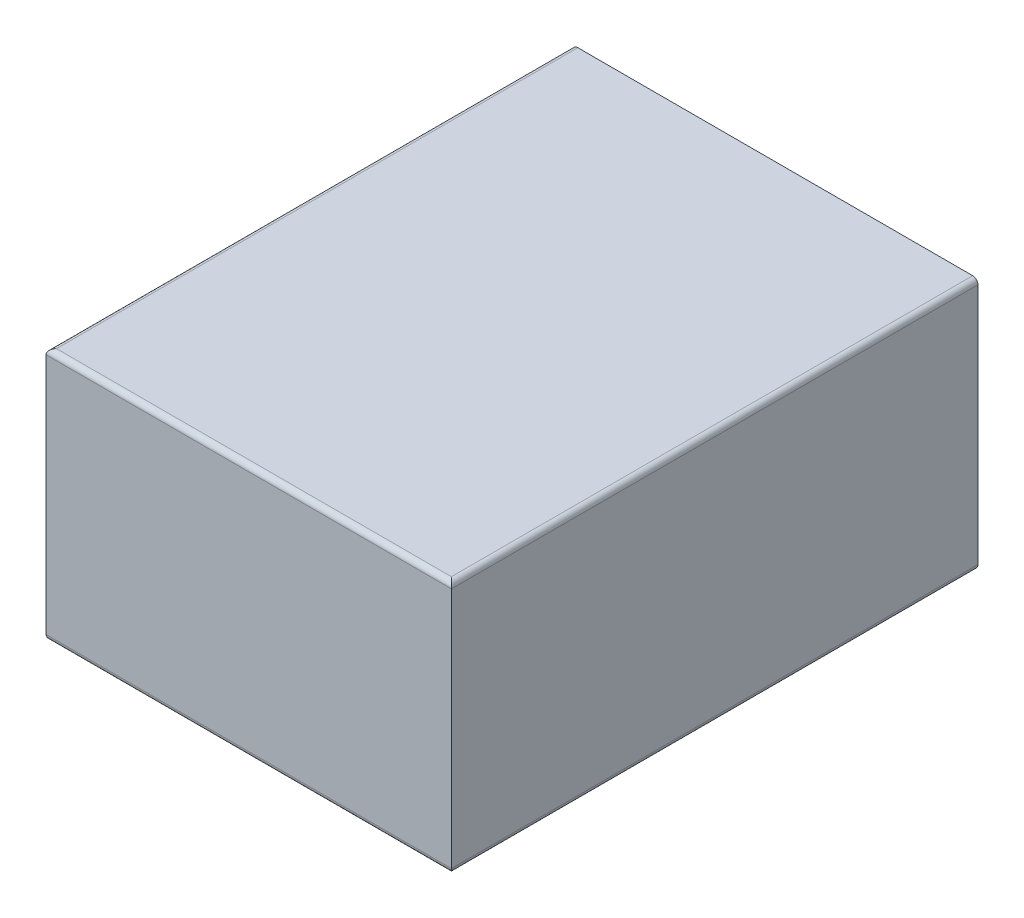
from build123d import *

# Parameters (mm, degrees)
CROQUIS1_W              = 770
CROQUIS1_H              = 480
SALIENTE_EXTRUIR1_DEPTH = 1000
REDONDEO1_R             = 10


with BuildPart() as part:
    # Croquis1 → Saliente-Extruir1 (new body)
    with BuildSketch(Plane.XY):
        Rectangle(CROQUIS1_W, CROQUIS1_H)
    extrude(amount=SALIENTE_EXTRUIR1_DEPTH)

    # Redondeo1
    redondeo1_edges = [part.edges().sort_by_distance(p)[0] for p in [
        (0, -240, 1000),
        (0, 240, 1000),
        (385, -240, 500),
        (-385, -240, 500),
        (-385, 240, 500),
        (385, 240, 500),
    ]]
    fillet(redondeo1_edges, radius=REDONDEO1_R)


solid = part.part
